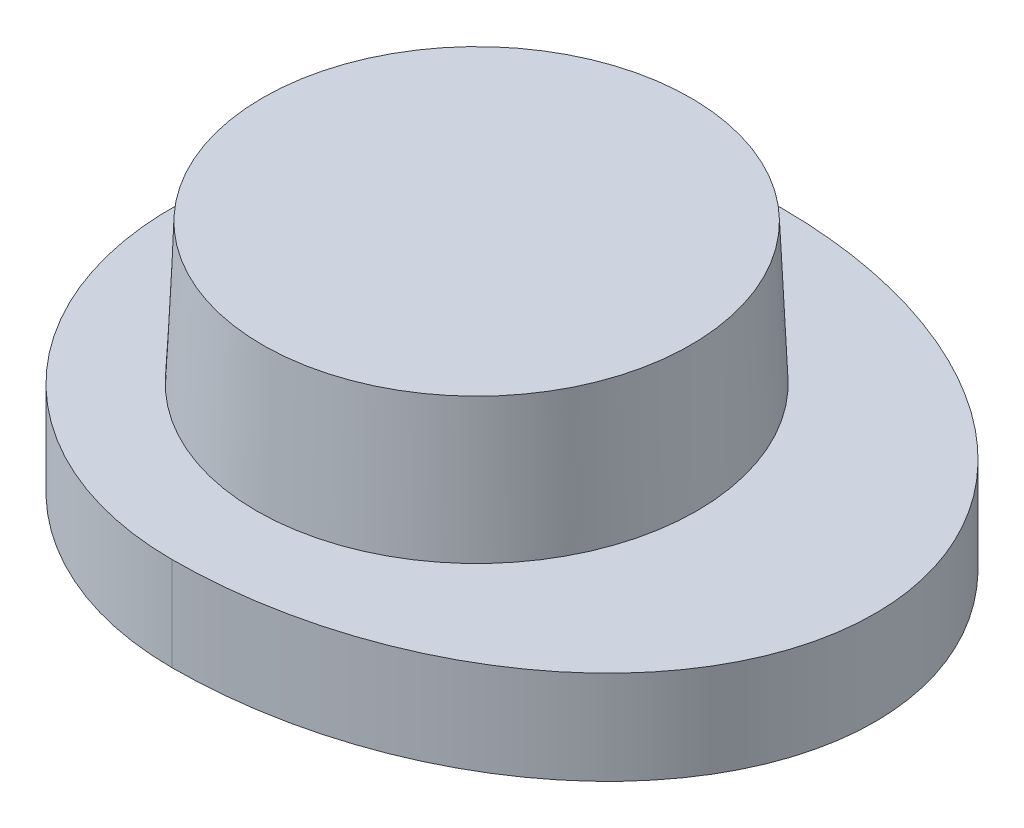
from build123d import *

# Parameters (mm, degrees)
BOSS_EXTRUDE4_DEPTH = 2.000034


with BuildPart() as part:
    # Sketch1 one side (on Front Plane) → Revolve25 (revolve)
    with BuildSketch(Plane.XY):
        with BuildLine():
            Line((-4.526114828, -19.925267112), (-4.682614804, -1.992146118))
            Line((-4.682614804, -1.992146118), (-4.7, 0))
            Line((-4.7, 0), (-6.5, 0))
            Line((-6.5, 0), (-6.5, -2))
            Line((-6.5, -2), (-5.582580535, -2))
            Line((-5.582580535, -2), (-5.425496915, -20))
            Line((-5.425496915, -20), (-2.794168337, -36.613554791))
            ThreePointArc((-2.794168337, -36.613554791), (-1.837287228, -38.322188957), (0, -39))
            Line((0, -39), (0, -38.1))
            ThreePointArc((0, -38.1), (-1.252783984, -37.637823588), (-1.905248831, -36.472763773))
            Line((-1.905248831, -36.472763773), (-4.526114828, -19.925267112))
        make_face()
    revolve(axis=Axis((0, 0, 0), (0, -1, 0)))


with BuildPart() as body_2:
    # Sketch1_10 one side → Revolve31 (revolve)
    with BuildSketch(Plane.XY):
        Polygon((26.569018636, 2.999966443), (22, 2.999966443), (22, 1.999966443), (26, 1.999966443), (26, -2.000033557), (28.5, -2.000033557), (28.5, 0), (26.7, 0), align=None)
    revolve(axis=Axis((22, 17.95552364, 0), (0, -1, 0)))

    # Sketch2 → Boss-Extrude4 (add)
    with BuildSketch(Plane(origin=(0, -2.000033557, 0), x_dir=(-1, 0, 0), z_dir=(0, -1, 0))):
        with BuildLine():
            Line((-22, 4), (-22, 6.5))
            add(Edge.make_bspline(
                [(-22, 6.5), (-30.5, 6.5), (-30.5, 0), (-30.5, -6.5), (-22, -6.5)],
                knots=[1.570796327, 1.570796327, 1.570796327, 3.141592654, 3.141592654, 4.71238898, 4.71238898, 4.71238898], degree=2, weights=[1, 0.707106781, 1, 0.707106781, 1]))
            Line((-22, -6.5), (-22, -4))
            ThreePointArc((-22, -4), (-26, 0), (-22, 4))
        make_face()
    extrude(amount=-BOSS_EXTRUDE4_DEPTH)


solid = body_2.part
